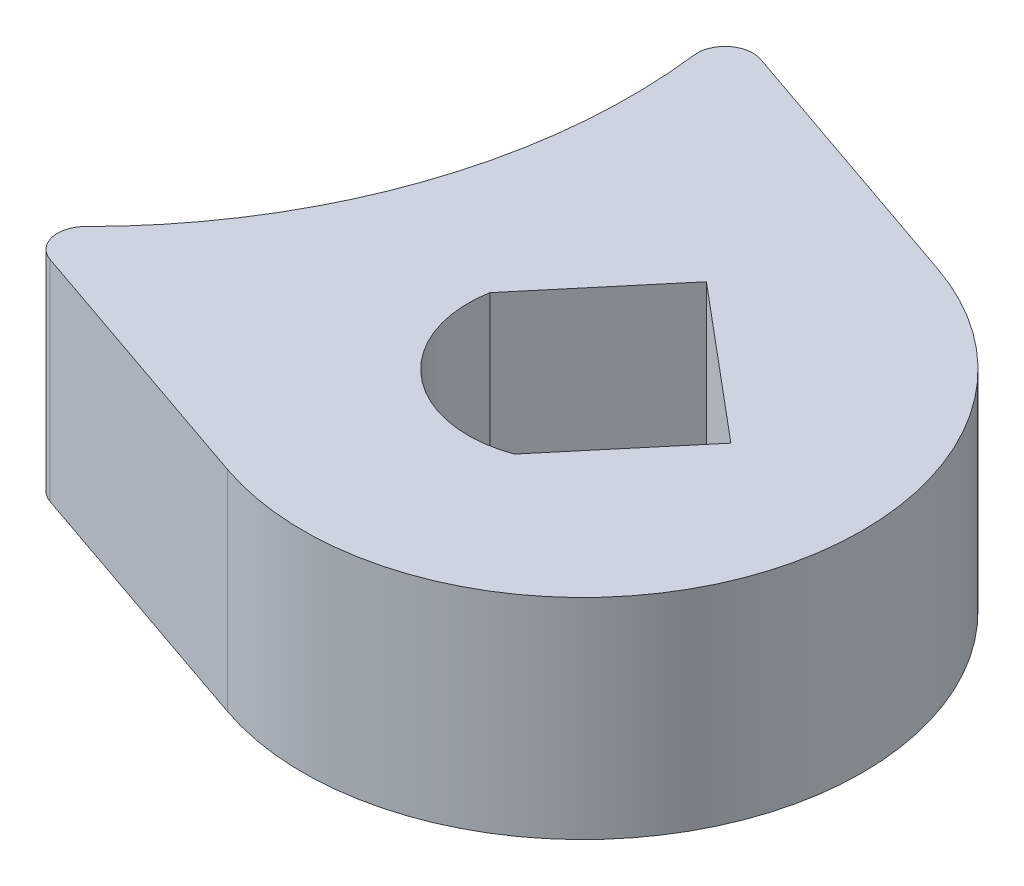
from build123d import *

# Parameters (mm, degrees)
BOSS_EXTRUDE1_DEPTH = 19.05
FILLET2_R           = 2.54


with BuildPart() as part:
    # Sketch1 → Boss-Extrude1 (new body)
    with BuildSketch(Plane(origin=(0, 0, 0), x_dir=(1, 0, 0), z_dir=(0, 1, 0))):
        with BuildLine():
            Line((8.268195512, 24.01659724), (-20.350973655, 33.869320491))
            ThreePointArc((-20.350973655, 33.869320491), (-21.987516047, 7.569643596), (-36.887364678, -14.163873988))
            Line((-36.887364678, -14.163873988), (-8.268195512, -24.01659724))
            ThreePointArc((-8.268195512, -24.01659724), (24.01659724, -8.268195512), (8.268195512, 24.01659724))
        make_face()
        with BuildLine():
            Line((-1.272683846, 12.511236201), (12.542161641, 0.919204448))
            Line((12.542161641, 0.919204448), (3.562418734, -9.782436422))
            ThreePointArc((3.562418734, -9.782436422), (-6.691999093, -7.975213961), (-10.252426753, 1.809595331))
            Line((-10.252426753, 1.809595331), (-1.272683846, 12.511236201))
        make_face(mode=Mode.SUBTRACT)
    extrude(amount=BOSS_EXTRUDE1_DEPTH)

    # Fillet2
    fillet2_edges = [part.edges().sort_by_distance(p)[0] for p in [
        (-36.887364678, 9.525, 14.163873988),
        (-20.350973655, 9.525, -33.869320491),
    ]]
    fillet(fillet2_edges, radius=FILLET2_R)


solid = part.part
